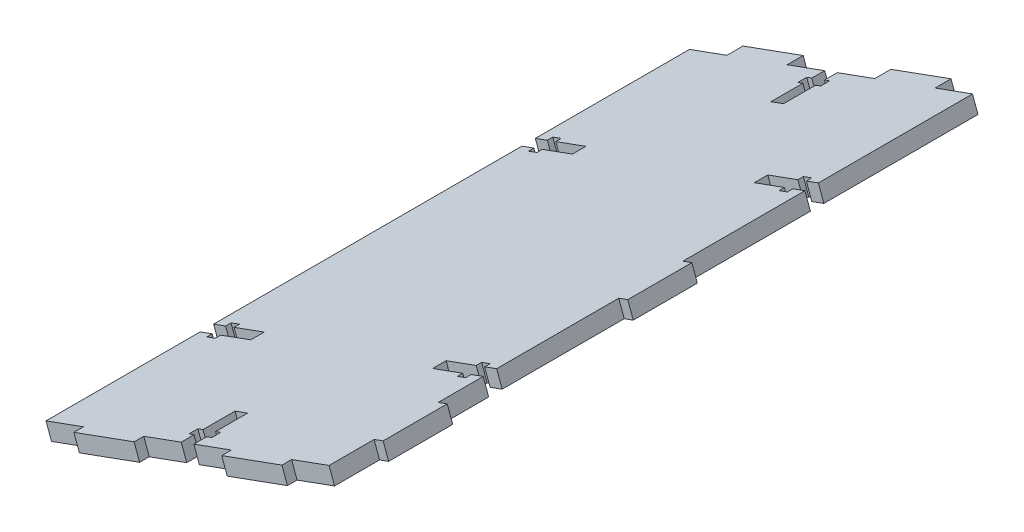
from build123d import *

# Parameters (mm, degrees)
BOSS_EXTRUDE1_DEPTH = 200.8
CUT_EXTRUDE3_DEPTH  = 36.191113799
SKETCH5_W           = 20
SKETCH5_H           = 5
SKETCH5_W_2         = 3
SKETCH5_H_2         = 20
SKETCH5_H_3         = 3
BOSS_EXTRUDE2_DEPTH = 5


with BuildPart() as part:
    # Sketch2 → Boss-Extrude1 (new body)
    with BuildSketch(Plane.XY.offset(2)):
        Polygon((22.534227339, 12.285835046), (24.243029584, 7.58689954), (-64.096957923, -24.53858267), (-65.805760168, -19.839647165), align=None)
    extrude(amount=BOSS_EXTRUDE1_DEPTH)

    # Sketch4 → Cut-Extrude3 (cut, through all)
    with BuildSketch(Plane(origin=(0.394814778, -1.085678102, 0), x_dir=(-0.939787101, -0.341760449, 0), z_dir=(0.341760449, -0.939787101, 0))):
        Polygon((19.52381131, -2), (23.72381131, -2), (23.72381131, -6), (25.42381131, -6), (25.42381131, -8.8), (23.72381131, -8.8), (23.72381131, -18.8), (19.52381131, -18.8), (19.52381131, -8.8), (17.82381131, -8.8), (17.82381131, -6), (19.52381131, -6), align=None)
        Polygon((-25.37618869, -54.3), (-25.37618869, -50.1), (-21.37618869, -50.1), (-21.37618869, -48.4), (-18.57618869, -48.4), (-18.57618869, -50.1), (-8.57618869, -50.1), (-8.57618869, -54.3), (-18.57618869, -54.3), (-18.57618869, -56), (-21.37618869, -56), (-21.37618869, -54.3), align=None)
        Polygon((23.72381131, -202.8), (19.52381131, -202.8), (19.52381131, -198.8), (17.82381131, -198.8), (17.82381131, -196), (19.52381131, -196), (19.52381131, -186), (23.72381131, -186), (23.72381131, -196), (25.42381131, -196), (25.42381131, -198.8), (23.72381131, -198.8), align=None)
        Polygon((-21.37618869, -154.7), (-21.37618869, -156.4), (-18.57618869, -156.4), (-18.57618869, -154.7), (-8.57618869, -154.7), (-8.57618869, -150.5), (-18.57618869, -150.5), (-18.57618869, -148.8), (-21.37618869, -148.8), (-21.37618869, -150.5), (-25.37618869, -150.5), (-25.37618869, -154.7), align=None)
        Polygon((68.62381131, -150.5), (68.62381131, -154.7), (64.62381131, -154.7), (64.62381131, -156.4), (61.82381131, -156.4), (61.82381131, -154.7), (51.82381131, -154.7), (51.82381131, -150.5), (61.82381131, -150.5), (61.82381131, -148.8), (64.62381131, -148.8), (64.62381131, -150.5), align=None)
        Polygon((64.62381131, -50.1), (64.62381131, -48.4), (61.82381131, -48.4), (61.82381131, -50.1), (51.82381131, -50.1), (51.82381131, -54.3), (61.82381131, -54.3), (61.82381131, -56), (64.62381131, -56), (64.62381131, -54.3), (68.62381131, -54.3), (68.62381131, -50.1), align=None)
    extrude(amount=-CUT_EXTRUDE3_DEPTH, mode=Mode.SUBTRACT)

    # Sketch5 → Boss-Extrude2 (add)
    with BuildSketch(Plane(origin=(0.394814778, -1.085678102, 0), x_dir=(0.939787101, 0.341760449, 0), z_dir=(0.341760449, -0.939787101, 0))):
        with Locations((2.92618869, -0.5)):
            Rectangle(SKETCH5_W, SKETCH5_H)
        with Locations((-46.17381131, -0.5)):
            Rectangle(SKETCH5_W, SKETCH5_H)
        with Locations((26.87618869, 102.4)):
            Rectangle(SKETCH5_W_2, SKETCH5_H_2)
        with Locations((26.87618869, 178.75)):
            Rectangle(SKETCH5_W_2, SKETCH5_H_2)
        with Locations((2.92618869, 204.3)):
            Rectangle(SKETCH5_W, SKETCH5_H_3)
        with Locations((-46.17381131, 204.3)):
            Rectangle(SKETCH5_W, SKETCH5_H_3)
    extrude(amount=-BOSS_EXTRUDE2_DEPTH)


solid = part.part
